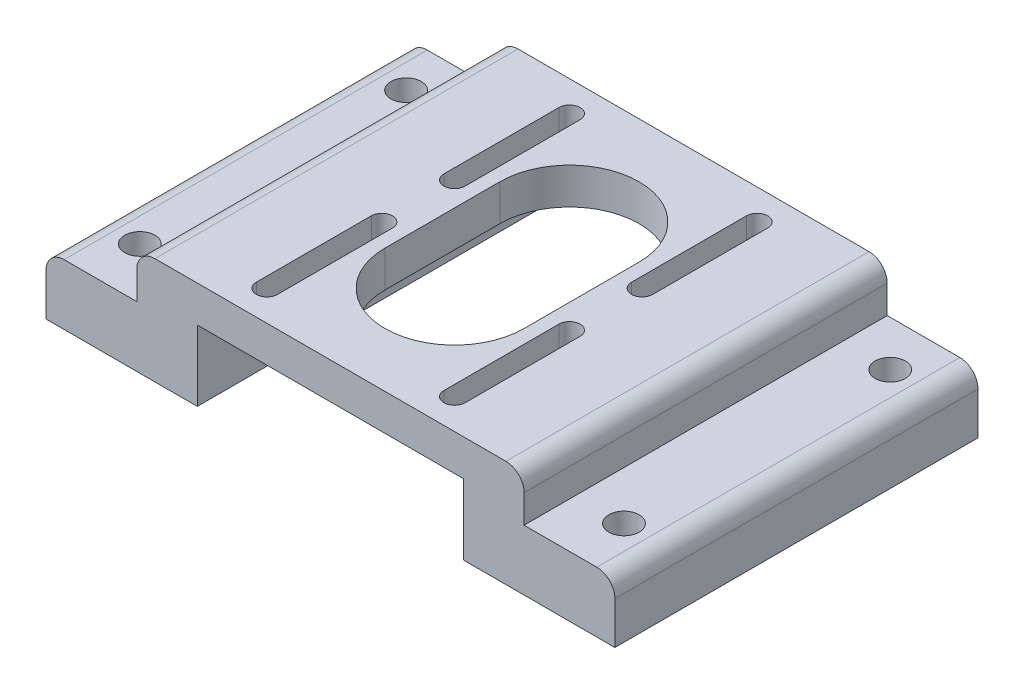
from build123d import *

# Parameters (mm, degrees)
BOSS_EXTRUDE1_DEPTH = 60
SKETCH2_R           = 2.5
CUT_EXTRUDE1_DEPTH  = 18.65
FILLET1_R           = 3


with BuildPart() as part:
    # Sketch1 → Boss-Extrude1 (new body)
    with BuildSketch(Plane.XY):
        Polygon((0, 0), (25, 0), (25, 11.65), (69, 11.65), (69, 0), (94, 0), (94, 10), (79, 10), (79, 17.65), (15, 17.65), (15, 10), (0, 10), align=None)
    extrude(amount=BOSS_EXTRUDE1_DEPTH)

    # Sketch2 → Cut-Extrude1 (cut, through all)
    with BuildSketch(Plane(origin=(0, 17.65, 0), x_dir=(1, 0, 0), z_dir=(0, 1, 0))):
        with Locations((7, -7.5)):
            Circle(SKETCH2_R)
        with Locations((7, -51.5)):
            Circle(SKETCH2_R)
        with Locations((87, -7.5)):
            Circle(SKETCH2_R)
        with Locations((87, -51.5)):
            Circle(SKETCH2_R)
        with BuildLine():
            Line((29.75, -36), (29.75, -55))
            ThreePointArc((29.75, -55), (31.5, -56.75), (33.25, -55))
            Line((33.25, -55), (33.25, -36))
            ThreePointArc((33.25, -36), (31.5, -34.25), (29.75, -36))
        make_face()
        with BuildLine():
            Line((29.75, -24), (29.75, -5))
            ThreePointArc((29.75, -5), (31.5, -3.25), (33.25, -5))
            Line((33.25, -5), (33.25, -24))
            ThreePointArc((33.25, -24), (31.5, -25.75), (29.75, -24))
        make_face()
        with BuildLine():
            Line((60.75, -5), (60.75, -24))
            ThreePointArc((60.75, -24), (62.5, -25.75), (64.25, -24))
            Line((64.25, -24), (64.25, -5))
            ThreePointArc((64.25, -5), (62.5, -3.25), (60.75, -5))
        make_face()
        with BuildLine():
            Line((60.75, -36), (60.75, -55))
            ThreePointArc((60.75, -55), (62.5, -56.75), (64.25, -55))
            Line((64.25, -55), (64.25, -36))
            ThreePointArc((64.25, -36), (62.5, -34.25), (60.75, -36))
        make_face()
        with BuildLine():
            Line((35.5, -20.5), (35.5, -39.5))
            ThreePointArc((35.5, -39.5), (47, -51), (58.5, -39.5))
            Line((58.5, -39.5), (58.5, -20.5))
            ThreePointArc((58.5, -20.5), (47, -9), (35.5, -20.5))
        make_face()
    extrude(amount=-CUT_EXTRUDE1_DEPTH, mode=Mode.SUBTRACT)

    # Fillet1
    fillet1_edges = [part.edges().sort_by_distance(p)[0] for p in [
        (0, 10, 30),
        (15, 17.65, 30),
        (79, 17.65, 30),
        (94, 10, 30),
    ]]
    fillet(fillet1_edges, radius=FILLET1_R)


solid = part.part
